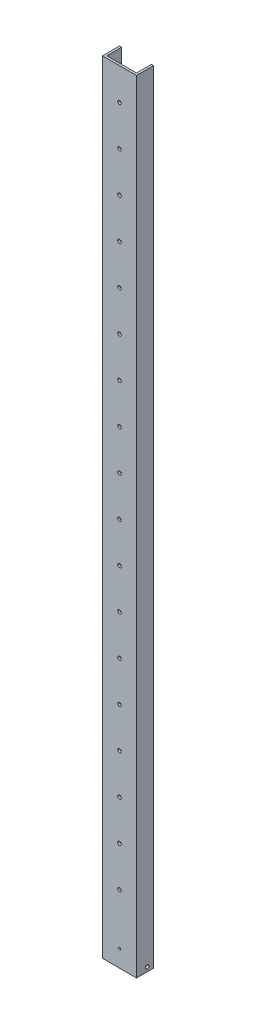
from build123d import *

# Parameters (mm, degrees)
BOSS_EXTRUDE1_DEPTH = 1168.4
IGUS_HOLES_REACH    = 27.4
SKETCH2_R           = 2.667
CUT_EXTRUDE2_REACH  = 5.175
SKETCH3_R           = 1.5875
SKETCH4_R           = 2.667
CUT_EXTRUDE3_DEPTH  = 51.8


with BuildPart() as part:
    # Sketch1 → Boss-Extrude1 (new body)
    with BuildSketch(Plane(origin=(0, 0, 0), x_dir=(1, 0, 0), z_dir=(0, 1, 0))):
        Polygon((3.175, 3.175), (3.175, 25.4), (0, 25.4), (0, 0), (50.8, 0), (50.8, 25.4), (47.625, 25.4), (47.625, 3.175), align=None)
    extrude(amount=BOSS_EXTRUDE1_DEPTH)

    # Sketch2 → Igus_Holes (cut, up to next)
    with BuildSketch(Plane.XY, mode=Mode.PRIVATE) as igus_holes_sk1:
        with Locations((25.4, 101.6)):
            Circle(SKETCH2_R)
    igus_holes_tool1 = extrude(igus_holes_sk1.sketch, amount=-IGUS_HOLES_REACH, mode=Mode.PRIVATE) & part.part
    add(igus_holes_tool1.solids().sort_by_distance((25.4, 101.6, 0))[0], mode=Mode.SUBTRACT)
    # Sketch2 → Igus_Holes (cut, up to next)
    with BuildSketch(Plane.XY, mode=Mode.PRIVATE) as igus_holes_sk2:
        with Locations((25.4, 161.544)):
            Circle(SKETCH2_R)
    igus_holes_tool2 = extrude(igus_holes_sk2.sketch, amount=-IGUS_HOLES_REACH, mode=Mode.PRIVATE) & part.part
    add(igus_holes_tool2.solids().sort_by_distance((25.4, 161.544, 0))[0], mode=Mode.SUBTRACT)
    # Sketch2 → Igus_Holes (cut, up to next)
    with BuildSketch(Plane.XY, mode=Mode.PRIVATE) as igus_holes_sk3:
        with Locations((25.4, 221.488)):
            Circle(SKETCH2_R)
    igus_holes_tool3 = extrude(igus_holes_sk3.sketch, amount=-IGUS_HOLES_REACH, mode=Mode.PRIVATE) & part.part
    add(igus_holes_tool3.solids().sort_by_distance((25.4, 221.488, 0))[0], mode=Mode.SUBTRACT)
    # Sketch2 → Igus_Holes (cut, up to next)
    with BuildSketch(Plane.XY, mode=Mode.PRIVATE) as igus_holes_sk4:
        with Locations((25.4, 281.432)):
            Circle(SKETCH2_R)
    igus_holes_tool4 = extrude(igus_holes_sk4.sketch, amount=-IGUS_HOLES_REACH, mode=Mode.PRIVATE) & part.part
    add(igus_holes_tool4.solids().sort_by_distance((25.4, 281.432, 0))[0], mode=Mode.SUBTRACT)
    # Sketch2 → Igus_Holes (cut, up to next)
    with BuildSketch(Plane.XY, mode=Mode.PRIVATE) as igus_holes_sk5:
        with Locations((25.4, 341.376)):
            Circle(SKETCH2_R)
    igus_holes_tool5 = extrude(igus_holes_sk5.sketch, amount=-IGUS_HOLES_REACH, mode=Mode.PRIVATE) & part.part
    add(igus_holes_tool5.solids().sort_by_distance((25.4, 341.376, 0))[0], mode=Mode.SUBTRACT)
    # Sketch2 → Igus_Holes (cut, up to next)
    with BuildSketch(Plane.XY, mode=Mode.PRIVATE) as igus_holes_sk6:
        with Locations((25.4, 401.32)):
            Circle(SKETCH2_R)
    igus_holes_tool6 = extrude(igus_holes_sk6.sketch, amount=-IGUS_HOLES_REACH, mode=Mode.PRIVATE) & part.part
    add(igus_holes_tool6.solids().sort_by_distance((25.4, 401.32, 0))[0], mode=Mode.SUBTRACT)
    # Sketch2 → Igus_Holes (cut, up to next)
    with BuildSketch(Plane.XY, mode=Mode.PRIVATE) as igus_holes_sk7:
        with Locations((25.4, 461.264)):
            Circle(SKETCH2_R)
    igus_holes_tool7 = extrude(igus_holes_sk7.sketch, amount=-IGUS_HOLES_REACH, mode=Mode.PRIVATE) & part.part
    add(igus_holes_tool7.solids().sort_by_distance((25.4, 461.264, 0))[0], mode=Mode.SUBTRACT)
    # Sketch2 → Igus_Holes (cut, up to next)
    with BuildSketch(Plane.XY, mode=Mode.PRIVATE) as igus_holes_sk8:
        with Locations((25.4, 521.208)):
            Circle(SKETCH2_R)
    igus_holes_tool8 = extrude(igus_holes_sk8.sketch, amount=-IGUS_HOLES_REACH, mode=Mode.PRIVATE) & part.part
    add(igus_holes_tool8.solids().sort_by_distance((25.4, 521.208, 0))[0], mode=Mode.SUBTRACT)
    # Sketch2 → Igus_Holes (cut, up to next)
    with BuildSketch(Plane.XY, mode=Mode.PRIVATE) as igus_holes_sk9:
        with Locations((25.4, 581.152)):
            Circle(SKETCH2_R)
    igus_holes_tool9 = extrude(igus_holes_sk9.sketch, amount=-IGUS_HOLES_REACH, mode=Mode.PRIVATE) & part.part
    add(igus_holes_tool9.solids().sort_by_distance((25.4, 581.152, 0))[0], mode=Mode.SUBTRACT)
    # Sketch2 → Igus_Holes (cut, up to next)
    with BuildSketch(Plane.XY, mode=Mode.PRIVATE) as igus_holes_sk10:
        with Locations((25.4, 641.096)):
            Circle(SKETCH2_R)
    igus_holes_tool10 = extrude(igus_holes_sk10.sketch, amount=-IGUS_HOLES_REACH, mode=Mode.PRIVATE) & part.part
    add(igus_holes_tool10.solids().sort_by_distance((25.4, 641.096, 0))[0], mode=Mode.SUBTRACT)
    # Sketch2 → Igus_Holes (cut, up to next)
    with BuildSketch(Plane.XY, mode=Mode.PRIVATE) as igus_holes_sk11:
        with Locations((25.4, 701.04)):
            Circle(SKETCH2_R)
    igus_holes_tool11 = extrude(igus_holes_sk11.sketch, amount=-IGUS_HOLES_REACH, mode=Mode.PRIVATE) & part.part
    add(igus_holes_tool11.solids().sort_by_distance((25.4, 701.04, 0))[0], mode=Mode.SUBTRACT)
    # Sketch2 → Igus_Holes (cut, up to next)
    with BuildSketch(Plane.XY, mode=Mode.PRIVATE) as igus_holes_sk12:
        with Locations((25.4, 760.984)):
            Circle(SKETCH2_R)
    igus_holes_tool12 = extrude(igus_holes_sk12.sketch, amount=-IGUS_HOLES_REACH, mode=Mode.PRIVATE) & part.part
    add(igus_holes_tool12.solids().sort_by_distance((25.4, 760.984, 0))[0], mode=Mode.SUBTRACT)
    # Sketch2 → Igus_Holes (cut, up to next)
    with BuildSketch(Plane.XY, mode=Mode.PRIVATE) as igus_holes_sk13:
        with Locations((25.4, 820.928)):
            Circle(SKETCH2_R)
    igus_holes_tool13 = extrude(igus_holes_sk13.sketch, amount=-IGUS_HOLES_REACH, mode=Mode.PRIVATE) & part.part
    add(igus_holes_tool13.solids().sort_by_distance((25.4, 820.928, 0))[0], mode=Mode.SUBTRACT)
    # Sketch2 → Igus_Holes (cut, up to next)
    with BuildSketch(Plane.XY, mode=Mode.PRIVATE) as igus_holes_sk14:
        with Locations((25.4, 880.872)):
            Circle(SKETCH2_R)
    igus_holes_tool14 = extrude(igus_holes_sk14.sketch, amount=-IGUS_HOLES_REACH, mode=Mode.PRIVATE) & part.part
    add(igus_holes_tool14.solids().sort_by_distance((25.4, 880.872, 0))[0], mode=Mode.SUBTRACT)
    # Sketch2 → Igus_Holes (cut, up to next)
    with BuildSketch(Plane.XY, mode=Mode.PRIVATE) as igus_holes_sk15:
        with Locations((25.4, 940.816)):
            Circle(SKETCH2_R)
    igus_holes_tool15 = extrude(igus_holes_sk15.sketch, amount=-IGUS_HOLES_REACH, mode=Mode.PRIVATE) & part.part
    add(igus_holes_tool15.solids().sort_by_distance((25.4, 940.816, 0))[0], mode=Mode.SUBTRACT)
    # Sketch2 → Igus_Holes (cut, up to next)
    with BuildSketch(Plane.XY, mode=Mode.PRIVATE) as igus_holes_sk16:
        with Locations((25.4, 1000.76)):
            Circle(SKETCH2_R)
    igus_holes_tool16 = extrude(igus_holes_sk16.sketch, amount=-IGUS_HOLES_REACH, mode=Mode.PRIVATE) & part.part
    add(igus_holes_tool16.solids().sort_by_distance((25.4, 1000.76, 0))[0], mode=Mode.SUBTRACT)
    # Sketch2 → Igus_Holes (cut, up to next)
    with BuildSketch(Plane.XY, mode=Mode.PRIVATE) as igus_holes_sk17:
        with Locations((25.4, 1060.704)):
            Circle(SKETCH2_R)
    igus_holes_tool17 = extrude(igus_holes_sk17.sketch, amount=-IGUS_HOLES_REACH, mode=Mode.PRIVATE) & part.part
    add(igus_holes_tool17.solids().sort_by_distance((25.4, 1060.704, 0))[0], mode=Mode.SUBTRACT)
    # Sketch2 → Igus_Holes (cut, up to next)
    with BuildSketch(Plane.XY, mode=Mode.PRIVATE) as igus_holes_sk18:
        with Locations((25.4, 1120.648)):
            Circle(SKETCH2_R)
    igus_holes_tool18 = extrude(igus_holes_sk18.sketch, amount=-IGUS_HOLES_REACH, mode=Mode.PRIVATE) & part.part
    add(igus_holes_tool18.solids().sort_by_distance((25.4, 1120.648, 0))[0], mode=Mode.SUBTRACT)

    # Sketch3 → Cut-Extrude2 (cut, up to next)
    with BuildSketch(Plane(origin=(0, 0, -3.175), x_dir=(-1, 0, 0), z_dir=(0, 0, -1)), mode=Mode.PRIVATE) as cut_extrude2_sk1:
        with Locations((-25.4, 25.4)):
            Circle(SKETCH3_R)
    cut_extrude2_tool1 = extrude(cut_extrude2_sk1.sketch, amount=-CUT_EXTRUDE2_REACH, mode=Mode.PRIVATE) & part.part
    add(cut_extrude2_tool1.solids().sort_by_distance((25.4, 25.4, -3.175))[0], mode=Mode.SUBTRACT)

    # Sketch4 → Cut-Extrude3 (cut, through all)
    with BuildSketch(Plane.ZY):
        with Locations((-15.875, 6.35)):
            Circle(SKETCH4_R)
    extrude(amount=-CUT_EXTRUDE3_DEPTH, mode=Mode.SUBTRACT)


solid = part.part
